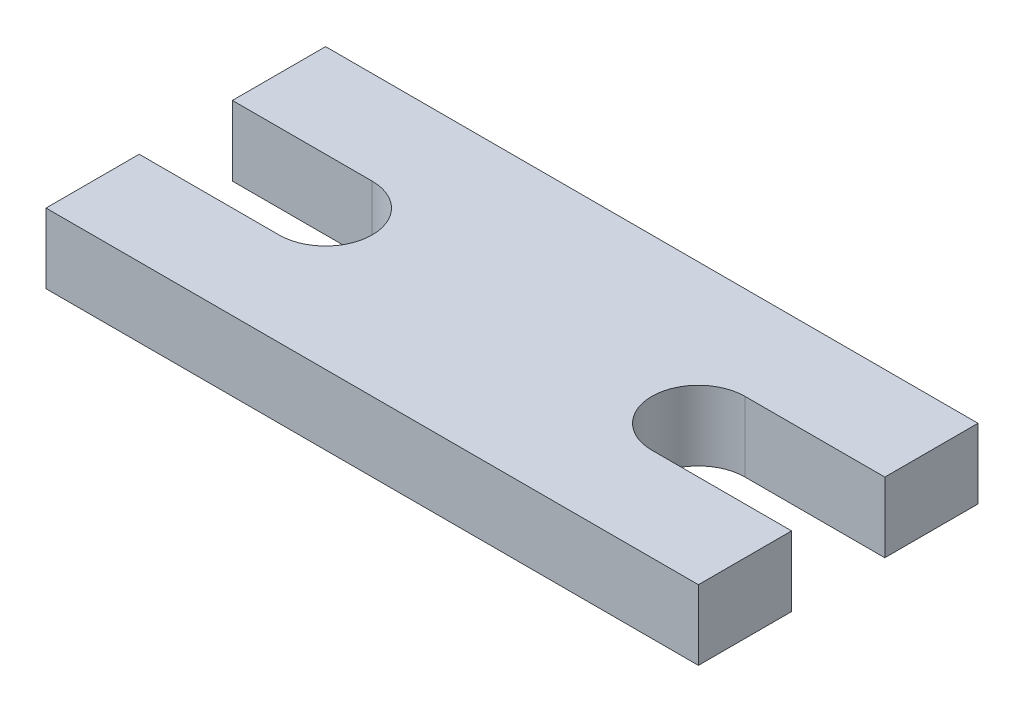
from build123d import *

# Parameters (mm, degrees)
SKETCH1_W           = 22.225
SKETCH1_H           = 9.525
BOSS_EXTRUDE1_DEPTH = 2.38125
CUT_EXTRUDE1_DEPTH  = 3.38125


with BuildPart() as part:
    # Sketch1 → Boss-Extrude1 (new body)
    with BuildSketch(Plane(origin=(0, 0, 0), x_dir=(1, 0, 0), z_dir=(0, 1, 0))):
        with Locations((11.1125, 4.7625)):
            Rectangle(SKETCH1_W, SKETCH1_H)
    extrude(amount=BOSS_EXTRUDE1_DEPTH)

    # Sketch2 → Cut-Extrude1 (cut, through all)
    with BuildSketch(Plane(origin=(0, 2.38125, 0), x_dir=(1, 0, 0), z_dir=(0, 1, 0))):
        with BuildLine():
            Line((0, 3.175), (4.7625, 3.175))
            ThreePointArc((4.7625, 3.175), (6.35, 4.7625), (4.7625, 6.35))
            Line((4.7625, 6.35), (0, 6.35))
            Line((0, 6.35), (0, 3.175))
        make_face()
        with BuildLine():
            Line((22.225, 6.35), (22.225, 3.175))
            Line((22.225, 3.175), (17.4625, 3.175))
            ThreePointArc((17.4625, 3.175), (15.875, 4.7625), (17.4625, 6.35))
            Line((17.4625, 6.35), (22.225, 6.35))
        make_face()
    extrude(amount=-CUT_EXTRUDE1_DEPTH, mode=Mode.SUBTRACT)


solid = part.part
